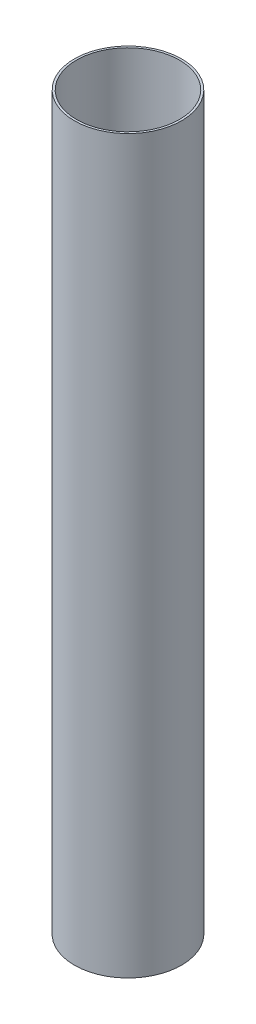
from build123d import *

# Parameters (mm, degrees)
SKETCH1_R           = 39.6748
SKETCH1_R_2         = 38.1
BOSS_EXTRUDE1_DEPTH = 270.51


with BuildPart() as part:
    # Sketch1 → Boss-Extrude1 (new body, symmetric)
    with BuildSketch(Plane(origin=(0, 0, 0), x_dir=(1, 0, 0), z_dir=(0, 1, 0))):
        Circle(SKETCH1_R)
        Circle(SKETCH1_R_2, mode=Mode.SUBTRACT)
    extrude(amount=BOSS_EXTRUDE1_DEPTH, both=True)


solid = part.part
